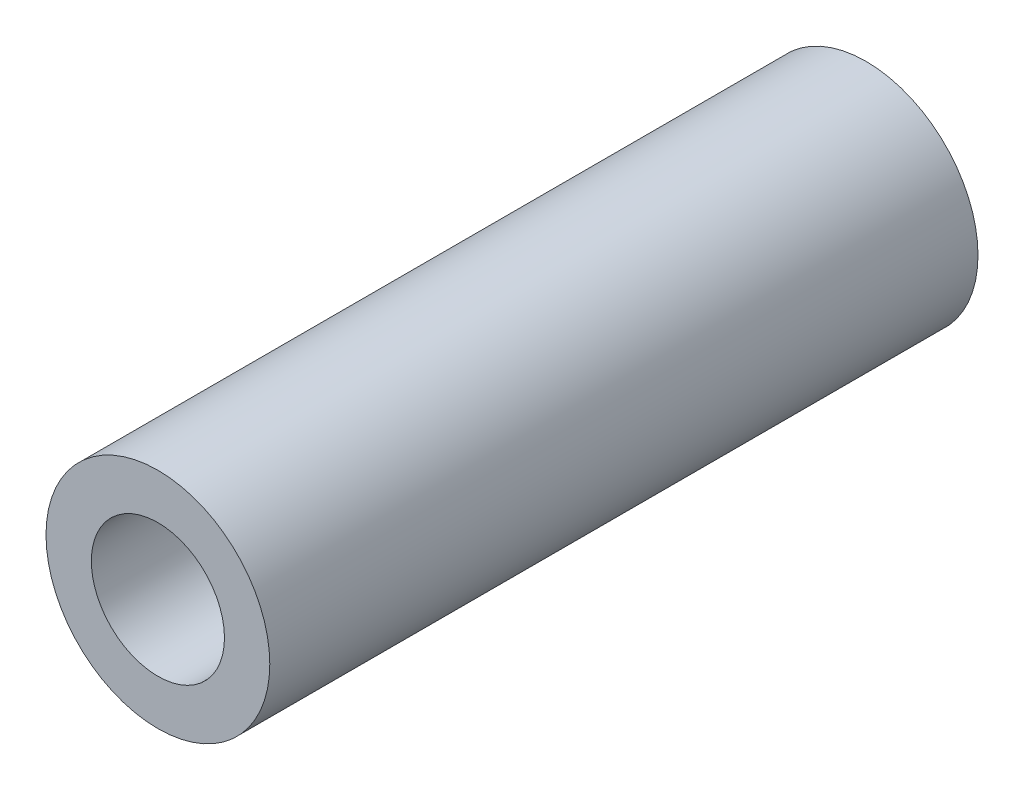
from build123d import *

# Parameters (mm, degrees)
SKETCH1_R           = 7.9
SKETCH1_R_2         = 4.7
BOSS_EXTRUDE1_DEPTH = 50


with BuildPart() as part:
    # Sketch1 → Boss-Extrude1 (new body)
    with BuildSketch(Plane.XY):
        Circle(SKETCH1_R)
        Circle(SKETCH1_R_2, mode=Mode.SUBTRACT)
    extrude(amount=-BOSS_EXTRUDE1_DEPTH)


solid = part.part
